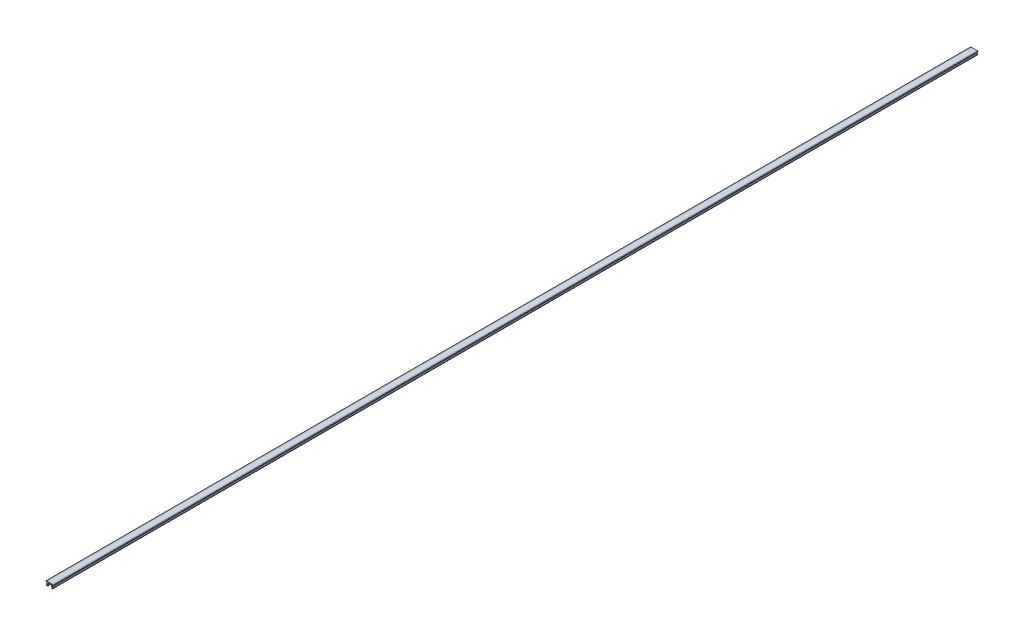
from build123d import *

# Parameters (mm, degrees)
EXTRUDE_1_DEPTH = 1000


with BuildPart() as part:
    # Эскиз1 → Бобышка-Вытянуть1 (new body)
    with BuildSketch(Plane.XY):
        with BuildLine():
            Line((-3.1, 0), (-4, -0.158694283))
            Line((-4, -0.158694283), (-4, -0.8))
            Line((-4, -0.8), (-3.1, -0.8))
            Line((-3.1, -0.8), (-3.1, -2.196152423))
            Line((-3.1, -2.196152423), (-3.68771324, -3.214101615))
            Line((-3.68771324, -3.214101615), (-3.1, -4.232050808))
            ThreePointArc((-3.1, -4.232050808), (-2.497197677, -4.481739705), (-2.1, -3.964101615))
            Line((-2.1, -3.964101615), (-2.533012702, -3.214101615))
            Line((-2.533012702, -3.214101615), (-2.1, -2.464101615))
            Line((-2.1, -2.464101615), (-2.1, -1))
            Line((-2.1, -1), (2.1, -1))
            Line((2.1, -1), (2.1, -2.464101615))
            Line((2.1, -2.464101615), (2.533012702, -3.214101615))
            Line((2.533012702, -3.214101615), (2.1, -3.964101615))
            ThreePointArc((2.1, -3.964101615), (2.497197677, -4.481739705), (3.1, -4.232050808))
            Line((3.1, -4.232050808), (3.68771324, -3.214101615))
            Line((3.68771324, -3.214101615), (3.1, -2.196152423))
            Line((3.1, -2.196152423), (3.1, -0.8))
            Line((3.1, -0.8), (4, -0.8))
            Line((4, -0.8), (4, -0.158694283))
            Line((4, -0.158694283), (3.1, 0))
            Line((3.1, 0), (-3.1, 0))
        make_face()
    extrude(amount=EXTRUDE_1_DEPTH)


solid = part.part
